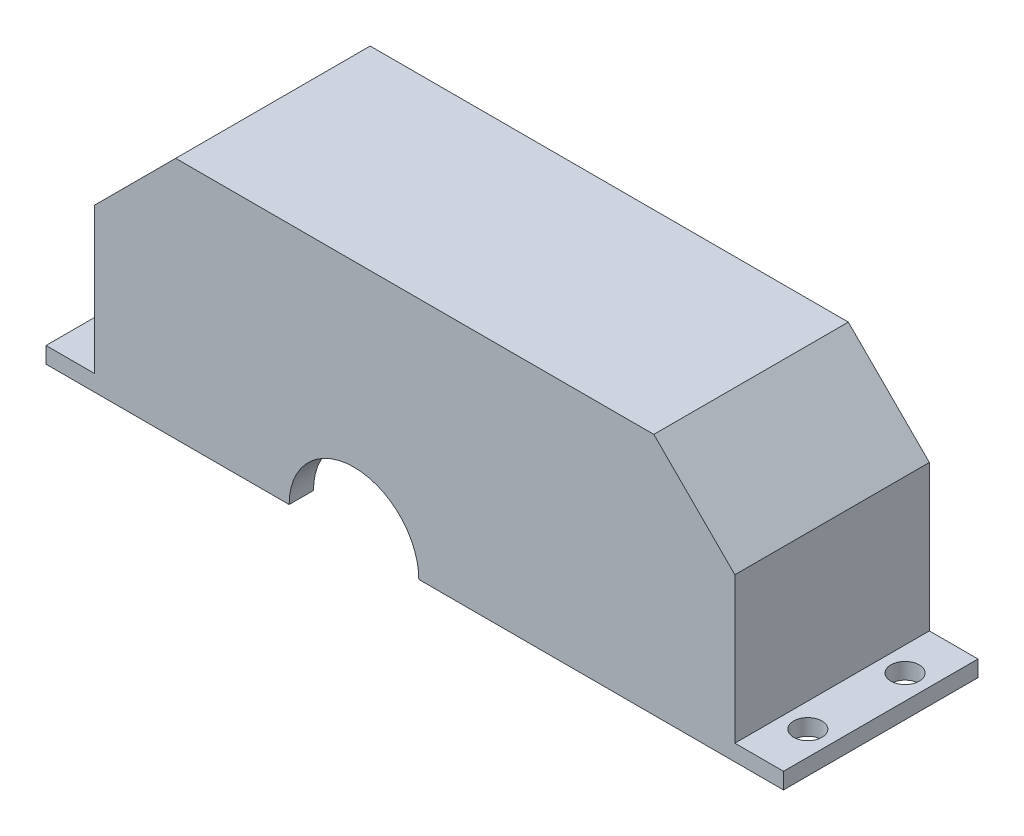
from build123d import *

# Parameters (mm, degrees)
SALIENTE_EXTRUIR1_DEPTH    = 5
SALIENTE_EXTRUIR4_DEPTH    = 15
SALIENTE_EXTRUIR6_DEPTH    = 3
SALIENTE_EXTRUIR10_DEPTH   = 1
CROQUIS8_W                 = 24
CROQUIS8_H                 = 2
SALIENTE_EXTRUIR8_DEPTH    = 6
CROQUIS18_W                = 24
CROQUIS18_H                = 2
SALIENTE_EXTRUIR14_DEPTH   = 6
CROQUIS12_R                = 1.75
CORTAR_EXTRUIR1_DEPTH      = 29
CORTAR_EXTRUIR1_DEPTH_BACK = 3
CHAFL_N4_SIZE              = 7
CHAFL_N5_SIZE              = 10
REDONDEO1_R                = 3


with BuildPart() as part:
    # Croquis1 → Saliente-Extruir1 (new body)
    with BuildSketch(Plane.XY):
        with BuildLine():
            Line((0, 0), (24, 0))
            ThreePointArc((24, 0), (32, 8), (40, 0))
            Line((40, 0), (46, 0))
            Line((46, 0), (46, 12))
            Line((46, 12), (73, 12))
            Line((73, 12), (73, 0))
            Line((73, 0), (79, 0))
            Line((79, 0), (79, 30))
            Line((79, 30), (0, 30))
            Line((0, 30), (0, 0))
        make_face()
    extrude(amount=SALIENTE_EXTRUIR1_DEPTH)

    # Croquis4 → Saliente-Extruir4 (add)
    with BuildSketch(Plane.XY.offset(5)):
        Polygon((0, 30), (0, 0), (3, 0), (3, 27), (76, 27), (76, 0), (79, 0), (79, 30), align=None)
    extrude(amount=SALIENTE_EXTRUIR4_DEPTH)

    # Croquis6 → Saliente-Extruir6 (add)
    with BuildSketch(Plane.XY.offset(20)):
        with BuildLine():
            Line((0, 0), (0, 30))
            Line((0, 30), (79, 30))
            Line((79, 30), (79, 0))
            Line((79, 0), (40, 0))
            ThreePointArc((40, 0), (32, 8), (24, 0))
            Line((24, 0), (0, 0))
        make_face()
    extrude(amount=SALIENTE_EXTRUIR6_DEPTH)

    # Croquis13 → Saliente-Extruir10 (add)
    with BuildSketch(Plane(origin=(0, 0, 0), x_dir=(-1, 0, 0), z_dir=(0, 0, -1))):
        with BuildLine():
            Line((-79, 30), (-79, 0))
            Line((-79, 0), (-73, 0))
            Line((-73, 0), (-73, 12))
            Line((-73, 12), (-46, 12))
            Line((-46, 12), (-46, 0))
            Line((-46, 0), (-40, 0))
            Line((-40, 0), (-38, 0))
            ThreePointArc((-38, 0), (-32, 6), (-26, 0))
            Line((-26, 0), (0, 0))
            Line((0, 0), (0, 30))
            Line((0, 30), (-79, 30))
        make_face()
    extrude(amount=SALIENTE_EXTRUIR10_DEPTH)

    # Croquis8 → Saliente-Extruir8 (add)
    with BuildSketch(Plane(origin=(79, 0, 0), x_dir=(0, 0, -1), z_dir=(1, 0, 0))):
        with Locations((-11, 1)):
            Rectangle(CROQUIS8_W, CROQUIS8_H)
    extrude(amount=SALIENTE_EXTRUIR8_DEPTH)

    # Croquis18 → Saliente-Extruir14 (add)
    with BuildSketch(Plane.ZY):
        with Locations((11, 1)):
            Rectangle(CROQUIS18_W, CROQUIS18_H)
    extrude(amount=SALIENTE_EXTRUIR14_DEPTH)

    # Croquis12 → Cortar-Extruir1 (cut, two sides)
    with BuildSketch(Plane(origin=(0, 2, 0), x_dir=(1, 0, 0), z_dir=(0, 1, 0))) as cortar_extruir1_sk:
        with Locations((-3, -5)):
            Circle(CROQUIS12_R)
        with Locations((-3, -17)):
            Circle(CROQUIS12_R)
        with Locations((82, -17)):
            Circle(CROQUIS12_R)
        with Locations((82, -5)):
            Circle(CROQUIS12_R)
    extrude(amount=CORTAR_EXTRUIR1_DEPTH, mode=Mode.SUBTRACT)
    extrude(cortar_extruir1_sk.sketch, amount=-CORTAR_EXTRUIR1_DEPTH_BACK, mode=Mode.SUBTRACT)

    # Chaflán4
    chafl_n4_edges = [part.edges().sort_by_distance(p)[0] for p in [
        (3, 27, 12.5),
        (76, 27, 12.5),
    ]]
    chamfer(chafl_n4_edges, length=CHAFL_N4_SIZE)

    # Chaflán5
    chafl_n5_edges = [part.edges().sort_by_distance(p)[0] for p in [
        (0, 30, 11),
        (79, 30, 11),
    ]]
    chamfer(chafl_n5_edges, length=CHAFL_N5_SIZE)

    # Redondeo1
    redondeo1_edges = [part.edges().sort_by_distance(p)[0] for p in [
        (73, 12, 2),
        (46, 12, 2),
    ]]
    fillet(redondeo1_edges, radius=REDONDEO1_R)


solid = part.part
